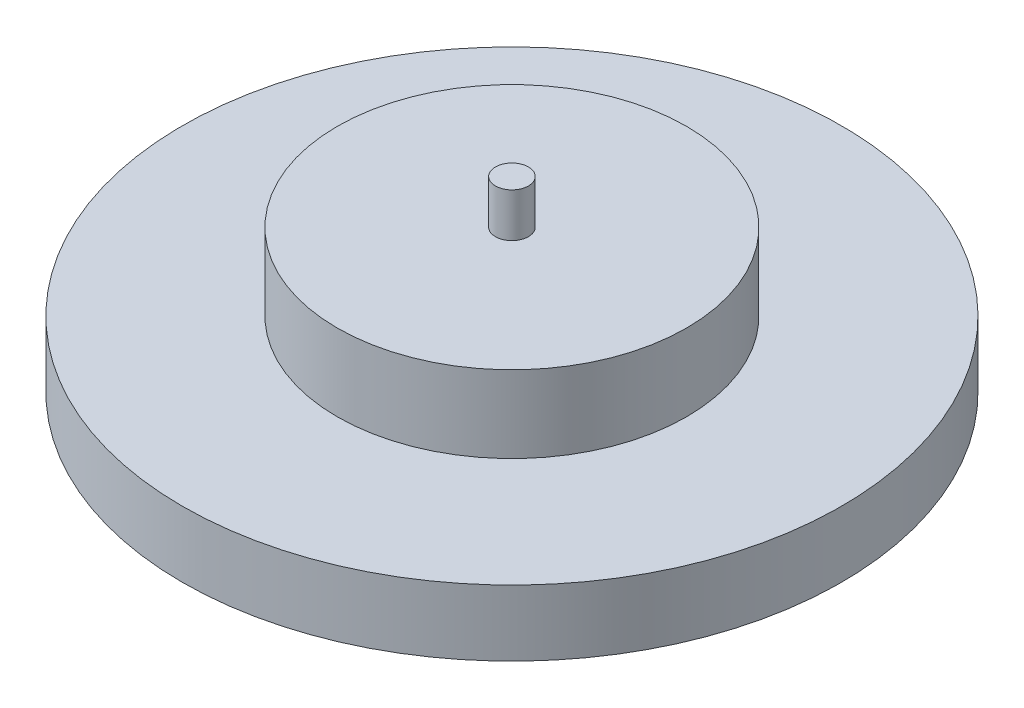
from build123d import *

# Parameters (mm, degrees)
SKETCH_1_R      = 15
EXTRUDE_1_DEPTH = 3
SKETCH_2_R      = 7.95
EXTRUDE_2_DEPTH = 3.5
SKETCH_3_R      = 0.75
EXTRUDE_3_DEPTH = 2


with BuildPart() as part:
    # 草图1 → 凸台-拉伸1 (new body)
    with BuildSketch(Plane(origin=(0, 0, 0), x_dir=(1, 0, 0), z_dir=(0, 1, 0))):
        Circle(SKETCH_1_R)
    extrude(amount=EXTRUDE_1_DEPTH)

    # 草图2 → 凸台-拉伸2 (add)
    with BuildSketch(Plane(origin=(0, 3, 0), x_dir=(1, 0, 0), z_dir=(0, 1, 0))):
        Circle(SKETCH_2_R)
    extrude(amount=EXTRUDE_2_DEPTH)

    # 草图3 → 凸台-拉伸3 (add)
    with BuildSketch(Plane(origin=(0, 6.5, 0), x_dir=(1, 0, 0), z_dir=(0, 1, 0))):
        Circle(SKETCH_3_R)
    extrude(amount=EXTRUDE_3_DEPTH)


solid = part.part
